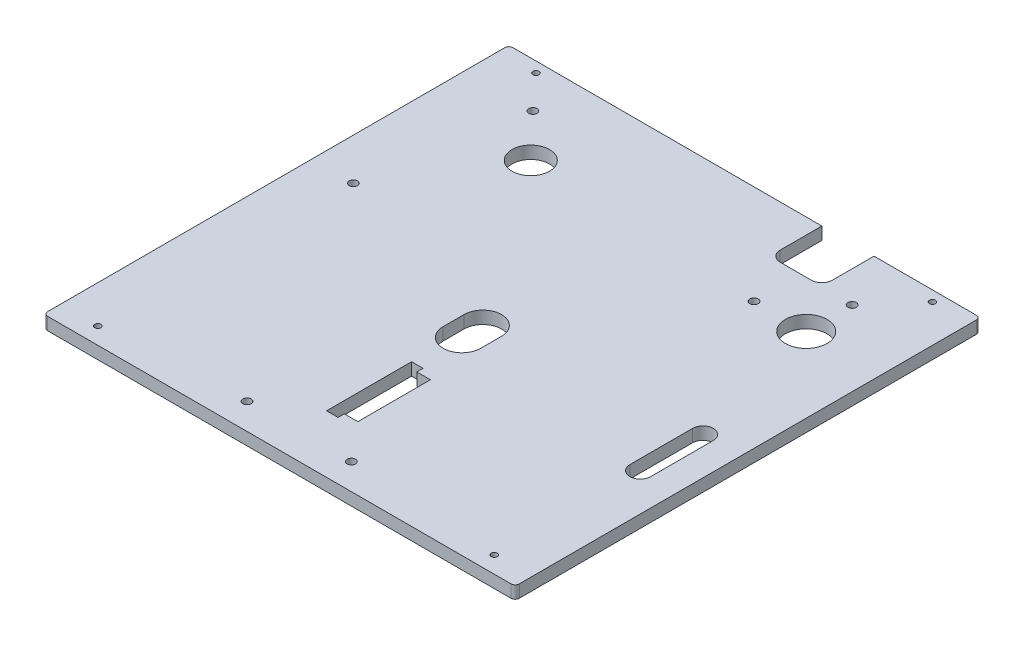
from build123d import *

# Parameters (mm, degrees)
SKETCH1_W           = 226
SKETCH1_H           = 223
SKETCH1_R           = 1.45
BOSS_EXTRUDE1_DEPTH = 6
SKETCH2_R           = 2
SKETCH2_R_2         = 9
SKETCH2_R_3         = 10
SKETCH2_W           = 25
SKETCH2_H           = 25
CUT_EXTRUDE1_DEPTH  = 7
FILLET1_R           = 5
FILLET2_R           = 2


with BuildPart() as part:
    # Sketch1 → Boss-Extrude1 (new body)
    with BuildSketch(Plane(origin=(0, 0, 0), x_dir=(1, 0, 0), z_dir=(0, 1, 0))):
        with Locations((0, -1.5)):
            Rectangle(SKETCH1_W, SKETCH1_H)
        with Locations((-95, -105)):
            Circle(SKETCH1_R, mode=Mode.SUBTRACT)
        with Locations((-95, 105)):
            Circle(SKETCH1_R, mode=Mode.SUBTRACT)
        with Locations((95, 105)):
            Circle(SKETCH1_R, mode=Mode.SUBTRACT)
        with Locations((95, -105)):
            Circle(SKETCH1_R, mode=Mode.SUBTRACT)
        Polygon((-5, -85.375), (0.5, -85.375), (0.5, -82.375), (7, -82.375), (7, -47.625), (0.5, -47.625), (0.5, -44.625), (-5, -44.625), align=None, mode=Mode.SUBTRACT)
        with BuildLine():
            Line((6, -12.5), (6, -22.5))
            ThreePointArc((6, -22.5), (-3, -31.5), (-12, -22.5))
            Line((-12, -22.5), (-12, -12.5))
            ThreePointArc((-12, -12.5), (-3, -3.5), (6, -12.5))
        make_face(mode=Mode.SUBTRACT)
    extrude(amount=BOSS_EXTRUDE1_DEPTH)

    # Sketch2 → Cut-Extrude1 (cut, through all)
    with BuildSketch(Plane(origin=(0, 6, 0), x_dir=(1, 0, 0), z_dir=(0, 1, 0))):
        with Locations((-28, -100.5)):
            Circle(SKETCH2_R)
        with Locations((22, -100.5)):
            Circle(SKETCH2_R)
        with Locations((-80, 88.5)):
            Circle(SKETCH2_R)
        with Locations((77, 84.5)):
            Circle(SKETCH2_R)
        with Locations((-93, 15.5)):
            Circle(SKETCH2_R)
        with Locations((52, 62.5)):
            Circle(SKETCH2_R)
        with Locations((-60, 67.5)):
            Circle(SKETCH2_R_2)
        with Locations((77, 62.5)):
            Circle(SKETCH2_R_3)
        with BuildLine():
            Line((90, -35), (90, -5))
            ThreePointArc((90, -5), (95, 0), (100, -5))
            Line((100, -5), (100, -35))
            ThreePointArc((100, -35), (95, -40), (90, -35))
        make_face()
        with Locations((49.5, 97.5)):
            Rectangle(SKETCH2_W, SKETCH2_H)
    extrude(amount=-CUT_EXTRUDE1_DEPTH, mode=Mode.SUBTRACT)

    # Fillet1
    fillet1_edges = [part.edges().sort_by_distance(p)[0] for p in [
        (62, 3, -85),
        (37, 3, -85),
    ]]
    fillet(fillet1_edges, radius=FILLET1_R)

    # Fillet2
    fillet2_edges = [part.edges().sort_by_distance(p)[0] for p in [
        (-113, 3, -110),
        (113, 3, -110),
        (113, 3, 113),
        (-113, 3, 113),
    ]]
    fillet(fillet2_edges, radius=FILLET2_R)


solid = part.part
